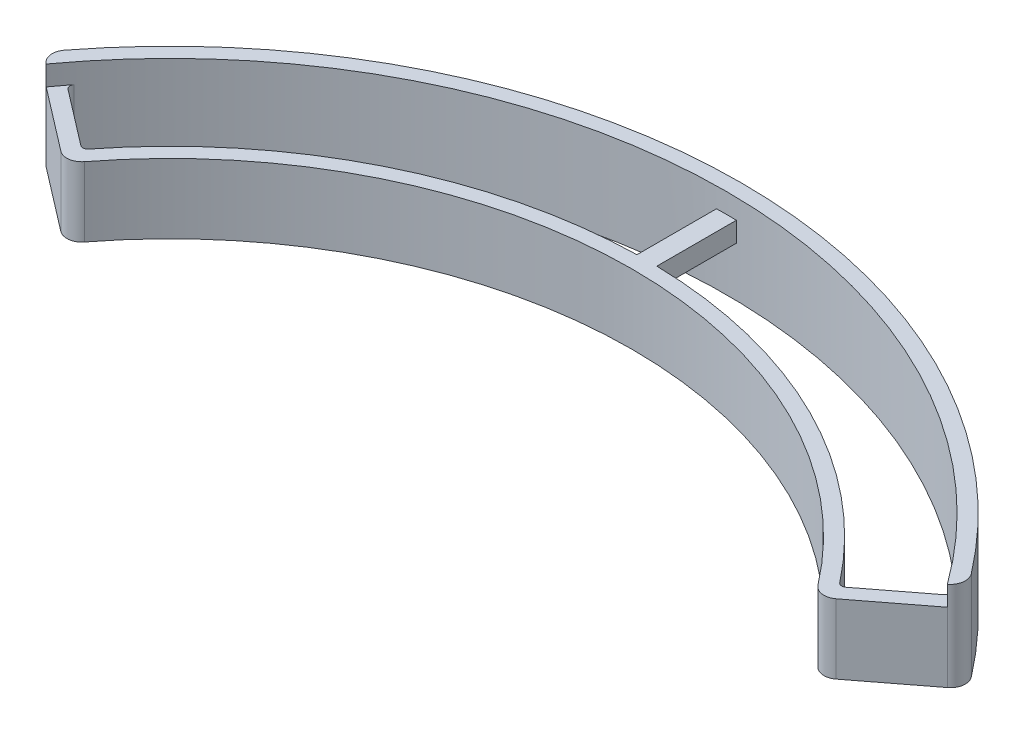
from build123d import *

# Parameters (mm, degrees)
BOSS_EXTRUDE1_DEPTH = 7
SKETCH2_W           = 2
SKETCH2_H           = 9.756485423
BOSS_EXTRUDE2_DEPTH = 2
BOSS_EXTRUDE3_DEPTH = 2
FILLET1_R           = 0.5
FILLET2_R           = 1.5


with BuildPart() as part:
    # Sketch1 → Boss-Extrude1 (new body)
    with BuildSketch(Plane(origin=(0, 0, 0), x_dir=(1, 0, 0), z_dir=(0, 1, 0))):
        with BuildLine():
            Line((37.784873439, 27.102644506), (46.515434438, 33.801839581))
            ThreePointArc((46.515434438, 33.801839581), (0, 57.5), (-46.515434438, 33.801839581))
            Line((-46.515434438, 33.801839581), (-37.784873439, 27.102644506))
            ThreePointArc((-37.784873439, 27.102644506), (0, 46.5), (37.784873439, 27.102644506))
        make_face()
        with BuildLine():
            Line((-38.080960334, 29.220548592), (-44.427787056, 34.090640024))
            ThreePointArc((-44.427787056, 34.090640024), (0, 56), (44.427787056, 34.090640024))
            Line((44.427787056, 34.090640024), (38.080960334, 29.220548592))
            ThreePointArc((38.080960334, 29.220548592), (0, 48), (-38.080960334, 29.220548592))
        make_face(mode=Mode.SUBTRACT)
    extrude(amount=-BOSS_EXTRUDE1_DEPTH)

    # Sketch2 → Boss-Extrude2 (add)
    with BuildSketch(Plane(origin=(0, 0, 0), x_dir=(1, 0, 0), z_dir=(0, 1, 0))):
        with Locations((0, 51.881238044)):
            Rectangle(SKETCH2_W, SKETCH2_H)
    extrude(amount=-BOSS_EXTRUDE2_DEPTH)

    # Sketch3 → Boss-Extrude3 (add)
    with BuildSketch(Plane(origin=(0, 0, 0), x_dir=(1, 0, 0), z_dir=(0, 1, 0))):
        with BuildLine():
            Line((45.324988438, 32.888378237), (46.515434438, 33.801839581))
            ThreePointArc((46.515434438, 33.801839581), (0, 57.5), (-46.515434438, 33.801839581))
            Line((-46.515434438, 33.801839581), (-45.324988438, 32.888378237))
            ThreePointArc((-45.324988438, 32.888378237), (0, 56), (45.324988438, 32.888378237))
        make_face()
    extrude(amount=BOSS_EXTRUDE3_DEPTH)

    # Fillet1
    fillet1_edges = [part.edges().sort_by_distance(p)[0] for p in [
        (-38.080960334, -3.5, -29.220548592),
        (-44.427787056, -3.5, -34.090640024),
        (38.080960334, -3.5, -29.220548592),
        (44.427787056, -3.5, -34.090640024),
    ]]
    fillet(fillet1_edges, radius=FILLET1_R)

    # Fillet2
    fillet2_edges = [part.edges().sort_by_distance(p)[0] for p in [
        (46.515434438, -2.5, -33.801839581),
        (37.784873439, -3.5, -27.102644506),
        (-37.784873439, -3.5, -27.102644506),
        (-46.515434438, -2.5, -33.801839581),
    ]]
    fillet(fillet2_edges, radius=FILLET2_R)


solid = part.part
